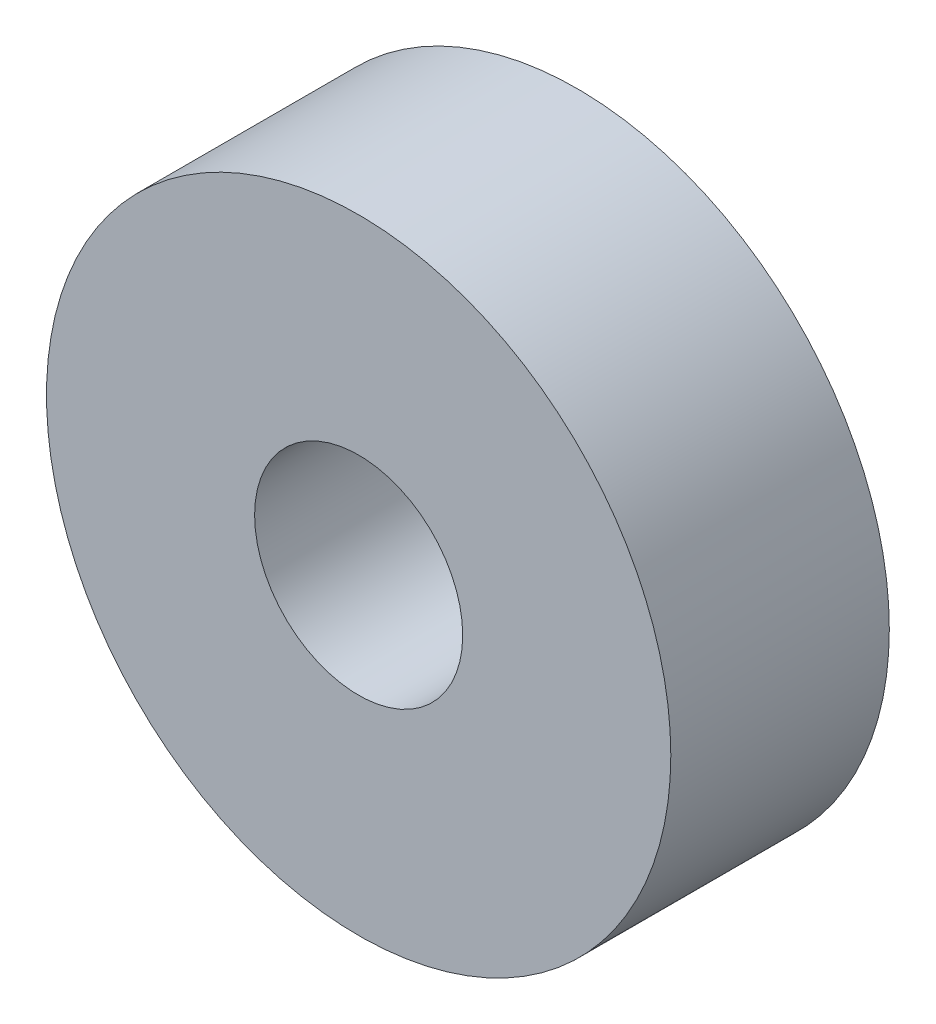
from build123d import *

# Parameters (mm, degrees)
SKETCH_1_R      = 15
SKETCH_1_R_2    = 5
EXTRUDE_1_DEPTH = 10.5


with BuildPart() as part:
    # 草图1 → 凸台-拉伸1 (new body)
    with BuildSketch(Plane.XY):
        Circle(SKETCH_1_R)
        Circle(SKETCH_1_R_2, mode=Mode.SUBTRACT)
    extrude(amount=EXTRUDE_1_DEPTH)


solid = part.part
